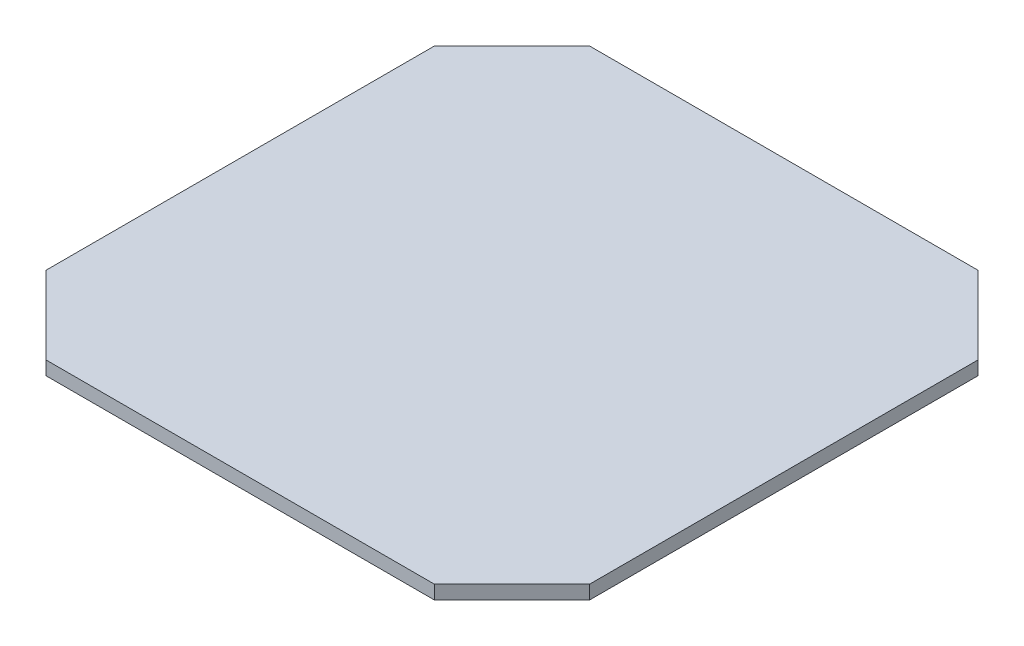
from build123d import *

# Parameters (mm, degrees)
BOSS_EXTRUDE1_DEPTH = 3.175


with BuildPart() as part:
    # Sketch1 → Boss-Extrude1 (new body)
    with BuildSketch(Plane(origin=(0, 0, 0), x_dir=(1, 0, 0), z_dir=(0, 1, 0))):
        Polygon((-62.861792847, -44.901280605), (-44.901280605, -62.861792847), (44.901280605, -62.861792847), (62.861792847, -44.901280605), (62.861792847, 44.901280605), (44.901280605, 62.861792847), (-44.901280605, 62.861792847), (-62.861792847, 44.901280605), align=None)
    extrude(amount=BOSS_EXTRUDE1_DEPTH)


solid = part.part
